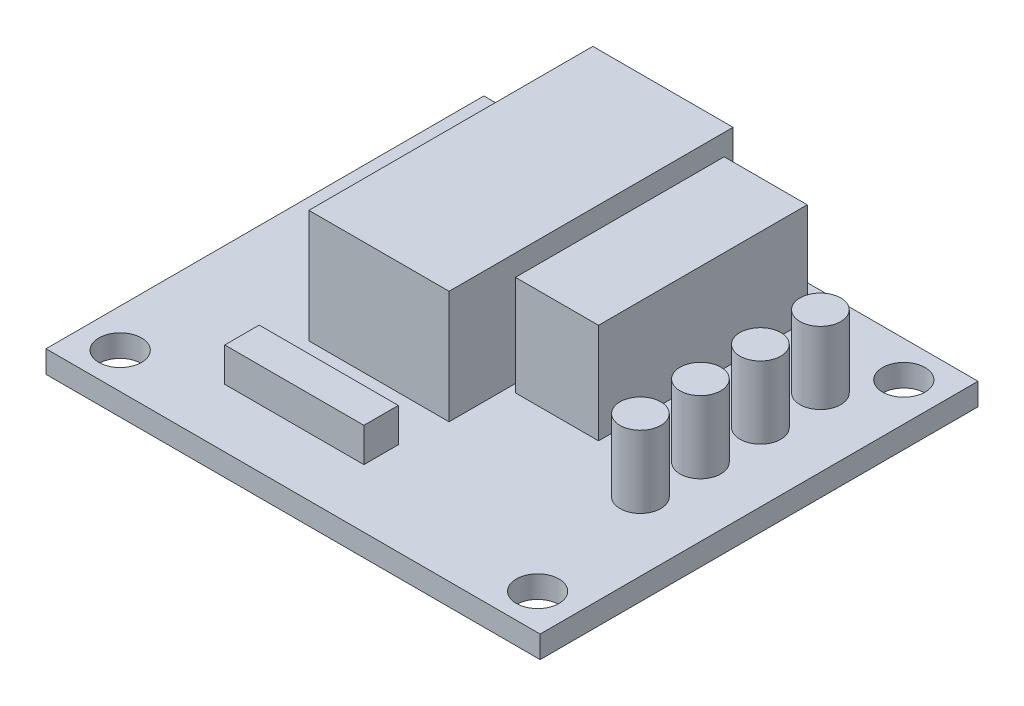
from build123d import *

# Parameters (mm, degrees)
SKETCH1_W           = 35.3568
SKETCH1_H           = 31.3309
SKETCH1_R           = 1.524
BOSS_EXTRUDE1_DEPTH = 1.5875
SKETCH2_W           = 2.4638
SKETCH2_H           = 9.9568
SKETCH2_W_2         = 9.9568
SKETCH2_H_2         = 2.4638
BOSS_EXTRUDE2_DEPTH = 2.4384
SKETCH3_W           = 10.033
SKETCH3_H           = 20.32
BOSS_EXTRUDE3_DEPTH = 8.0899
SKETCH4_W           = 5.9436
SKETCH4_H           = 14.9352
BOSS_EXTRUDE4_DEPTH = 7.1628
SKETCH5_R           = 1.4605
BOSS_EXTRUDE5_DEPTH = 5.1562


with BuildPart() as part:
    # Sketch1 → Boss-Extrude1 (new body)
    with BuildSketch(Plane(origin=(0, 0, 0), x_dir=(1, 0, 0), z_dir=(0, 1, 0))):
        Rectangle(SKETCH1_W, SKETCH1_H)
        with Locations((14.9352, -13.10005)):
            Circle(SKETCH1_R, mode=Mode.SUBTRACT)
        with Locations((14.9352, 13.10005)):
            Circle(SKETCH1_R, mode=Mode.SUBTRACT)
        with Locations((-14.9352, -13.10005)):
            Circle(SKETCH1_R, mode=Mode.SUBTRACT)
        with Locations((-14.9352, 13.10005)):
            Circle(SKETCH1_R, mode=Mode.SUBTRACT)
    extrude(amount=BOSS_EXTRUDE1_DEPTH)

    # Sketch2 → Boss-Extrude2 (add)
    with BuildSketch(Plane(origin=(0, 1.5875, 0), x_dir=(1, 0, 0), z_dir=(0, 1, 0))):
        with Locations((-10.9347, 5.31495)):
            Rectangle(SKETCH2_W, SKETCH2_H)
        with Locations((-4.1021, -10.24255)):
            Rectangle(SKETCH2_W_2, SKETCH2_H_2)
    extrude(amount=BOSS_EXTRUDE2_DEPTH)

    # Sketch3 → Boss-Extrude3 (add)
    with BuildSketch(Plane(origin=(0, 1.5875, 0), x_dir=(1, 0, 0), z_dir=(0, 1, 0))):
        with Locations((-3.7465, 4.38785)):
            Rectangle(SKETCH3_W, SKETCH3_H)
    extrude(amount=BOSS_EXTRUDE3_DEPTH)

    # Sketch4 → Boss-Extrude4 (add)
    with BuildSketch(Plane(origin=(0, 1.5875, 0), x_dir=(1, 0, 0), z_dir=(0, 1, 0))):
        with Locations((4.826, 5.86105)):
            Rectangle(SKETCH4_W, SKETCH4_H)
    extrude(amount=BOSS_EXTRUDE4_DEPTH)

    # Sketch5 → Boss-Extrude5 (add)
    with BuildSketch(Plane(origin=(0, 1.5875, 0), x_dir=(1, 0, 0), z_dir=(0, 1, 0))):
        with Locations((12.7635, 9.30275)):
            Circle(SKETCH5_R)
        with Locations((12.7635, 5.01015)):
            Circle(SKETCH5_R)
        with Locations((12.7635, 0.71755)):
            Circle(SKETCH5_R)
        with Locations((12.7635, -3.57505)):
            Circle(SKETCH5_R)
    extrude(amount=BOSS_EXTRUDE5_DEPTH)


solid = part.part
